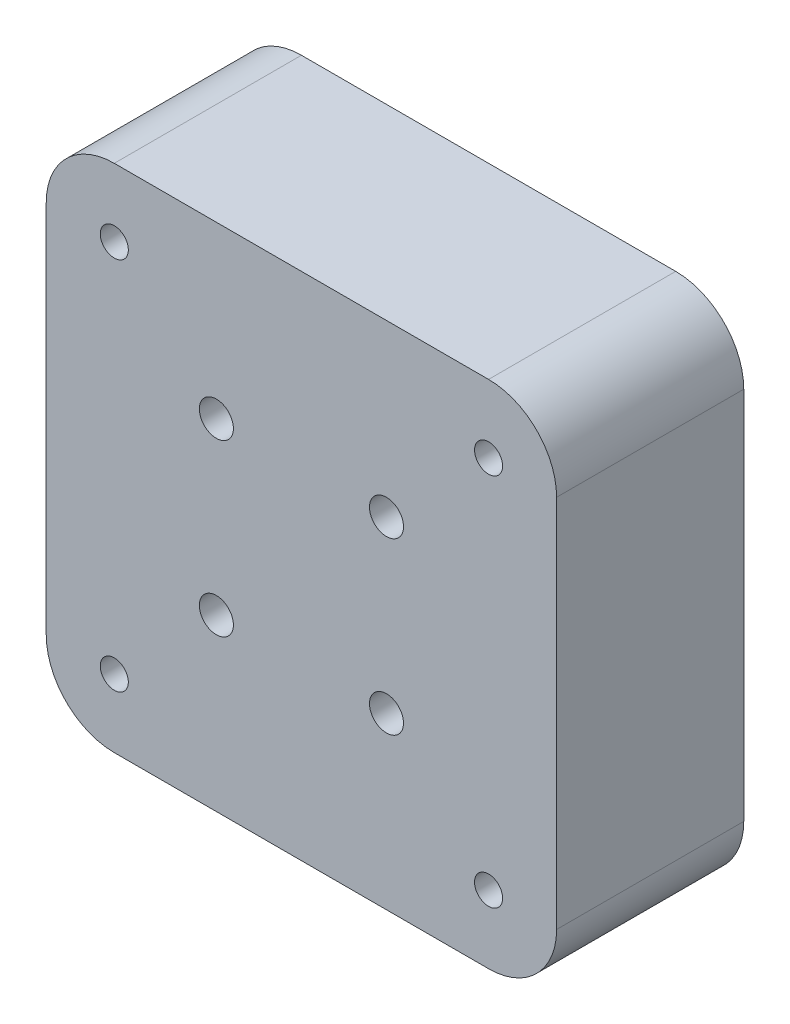
from build123d import *

# Parameters (mm, degrees)
SKETCH1_W             = 60
SKETCH1_H             = 60
BOSS_EXTRUDE1_DEPTH   = 22
FILLET1_R             = 8
M4X0_7_TAPPED_HOLE1_D = 3.3
CUT_EXTRUDE1_DEPTH    = 10
SKETCH6_R             = 2
CUT_EXTRUDE2_DEPTH    = 23


with BuildPart() as part:
    # Sketch1 → Boss-Extrude1 (new body)
    with BuildSketch(Plane.XY):
        Rectangle(SKETCH1_W, SKETCH1_H)
    extrude(amount=BOSS_EXTRUDE1_DEPTH)

    # Fillet1
    fillet1_edges = [part.edges().sort_by_distance(p)[0] for p in [
        (30, -30, 11),
        (-30, -30, 11),
        (-30, 30, 11),
        (30, 30, 11),
    ]]
    fillet(fillet1_edges, radius=FILLET1_R)

    # M4x0.7 Tapped Hole1 (through all)
    with Locations(Plane(origin=(0, 0, 0), x_dir=(-1, 0, 0), z_dir=(0, 0, -1))):
        with Locations((-22, 22), (22, 22), (22, -22), (-22, -22)):
            Hole(M4X0_7_TAPPED_HOLE1_D / 2)

    # Sketch5 → Cut-Extrude1 (cut)
    with BuildSketch(Plane(origin=(0, 0, 0), x_dir=(-1, 0, 0), z_dir=(0, 0, -1))):
        with BuildLine():
            Line((-15, 20), (15, 20))
            ThreePointArc((15, 20), (18.535533906, 18.535533906), (20, 15))
            Line((20, 15), (20, -15))
            ThreePointArc((20, -15), (18.535533906, -18.535533906), (15, -20))
            Line((15, -20), (-15, -20))
            ThreePointArc((-15, -20), (-18.535533906, -18.535533906), (-20, -15))
            Line((-20, -15), (-20, 15))
            ThreePointArc((-20, 15), (-18.535533906, 18.535533906), (-15, 20))
        make_face()
    extrude(amount=-CUT_EXTRUDE1_DEPTH, mode=Mode.SUBTRACT)

    # Sketch6 → Cut-Extrude2 (cut, through all)
    with BuildSketch(Plane.XY.offset(22)):
        with Locations((-10, 10)):
            Circle(SKETCH6_R)
        with Locations((10, 10)):
            Circle(SKETCH6_R)
        with Locations((10, -10)):
            Circle(SKETCH6_R)
        with Locations((-10, -10)):
            Circle(SKETCH6_R)
    extrude(amount=-CUT_EXTRUDE2_DEPTH, mode=Mode.SUBTRACT)


solid = part.part
